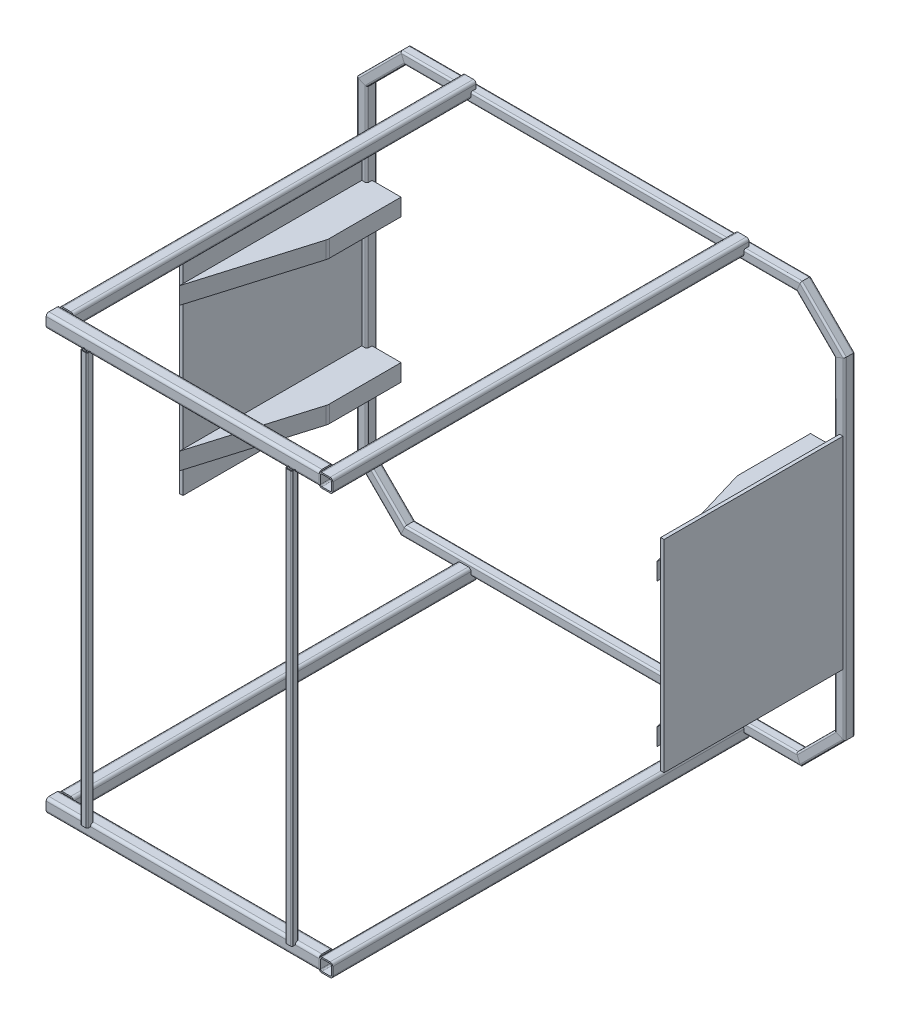
from build123d import *

# Parameters (mm, degrees)
SQUARE_TUBE_CONFIGURED_30_X_30_X_2_6_1_DEPTH      = 1169.786796564
SQUARE_TUBE_CONFIGURED_30_X_30_X_2_6_1_DEPTH_BACK = 9.786796564
SQUARE_TUBE_CONFIGURED_30_X_30_X_2_4_DEPTH        = 189.279220614
SQUARE_TUBE_CONFIGURED_30_X_30_X_2_6_DEPTH        = 979.573593129
SQUARE_TUBE_CONFIGURED_30_X_30_X_2_8_DEPTH        = 189.279220614
SQUARE_TUBE_CONFIGURED_30_X_30_X_2_10_DEPTH       = 1179.573593129
SQUARE_TUBE_CONFIGURED_30_X_30_X_2_13_DEPTH       = 189.279220614
SQUARE_TUBE_CONFIGURED_30_X_30_X_2_16_DEPTH       = 979.573593129
SQUARE_TUBE_CONFIGURED_30_X_30_X_2_19_DEPTH       = 189.279220614
SQUARE_TUBE_CONFIGURED_40_X_40_X_4_1_DEPTH        = 1220
SQUARE_TUBE_CONFIGURED_40_X_40_X_4_1_2_DEPTH      = 821
SQUARE_TUBE_CONFIGURED_40_X_40_X_4_1_3_DEPTH      = 1201
SQUARE_TUBE_CONFIGURED_40_X_40_X_4_4_DEPTH        = 1220
SQUARE_TUBE_CONFIGURED_40_X_40_X_4_4_2_DEPTH      = 821
SQUARE_TUBE_CONFIGURED_40_X_40_X_4_4_3_DEPTH      = 1201
SQUARE_TUBE_CONFIGURED_20_X_20_X_2_1_DEPTH        = 1206
SQUARE_TUBE_CONFIGURED_20_X_20_X_2_1_2_DEPTH      = 1206
DODANIE_WYCI_GNI_CIE1_DEPTH                       = 50
SZYK_LINIOWY1_COUNT                               = 2
SZYK_LINIOWY1_PITCH                               = 420
LUSTRO1_COPY_1_DEPTH                              = 50
SZKIC14_W                                         = 539.262552896
SZKIC14_H                                         = 591.984283132
DODANIE_WYCI_GNI_CIE2_DEPTH                       = 10
SZKIC15_W                                         = 539.262552896
SZKIC15_H                                         = 593.627508771
DODANIE_WYCI_GNI_CIE3_DEPTH                       = 10


with BuildPart() as part:
    # Sketch1 → Square tube - configured 30 X 30 X 2.6(1) (new, two sides)
    with BuildSketch(Plane(origin=(-580, 600, 0), x_dir=(0, 0, -1), z_dir=(1, 0, 0))) as square_tube_configured_30_x_30_x_2_6_1_sk:
        with BuildLine():
            Line((-9.8, -15), (9.8, -15))
            ThreePointArc((9.8, -15), (13.476955262, -13.476955262), (15, -9.8))
            Line((15, -9.8), (15, 9.8))
            ThreePointArc((15, 9.8), (13.476955262, 13.476955262), (9.8, 15))
            Line((9.8, 15), (-9.8, 15))
            ThreePointArc((-9.8, 15), (-13.476955262, 13.476955262), (-15, 9.8))
            Line((-15, 9.8), (-15, -9.8))
            ThreePointArc((-15, -9.8), (-13.476955262, -13.476955262), (-9.8, -15))
        make_face()
        with BuildLine():
            Line((-9.8, -12.4), (9.8, -12.4))
            ThreePointArc((9.8, -12.4), (11.638477631, -11.638477631), (12.4, -9.8))
            Line((12.4, -9.8), (12.4, 9.8))
            ThreePointArc((12.4, 9.8), (11.638477631, 11.638477631), (9.8, 12.4))
            Line((9.8, 12.4), (-9.8, 12.4))
            ThreePointArc((-9.8, 12.4), (-11.638477631, 11.638477631), (-12.4, 9.8))
            Line((-12.4, 9.8), (-12.4, -9.8))
            ThreePointArc((-12.4, -9.8), (-11.638477631, -11.638477631), (-9.8, -12.4))
        make_face(mode=Mode.SUBTRACT)
    extrude(amount=SQUARE_TUBE_CONFIGURED_30_X_30_X_2_6_1_DEPTH)
    extrude(square_tube_configured_30_x_30_x_2_6_1_sk.sketch, amount=-SQUARE_TUBE_CONFIGURED_30_X_30_X_2_6_1_DEPTH_BACK)

    # Square tube - configured 30 X 30 X 2 2
    split(bisect_by=Plane(origin=(-580, 600, 0), x_dir=(-0.382683432, 0.923879533, 0), z_dir=(0.923879533, 0.382683432, 0)), keep=Keep.TOP)

    # Square tube - configured 30 X 30 X 2 3
    split(bisect_by=Plane(origin=(580, 600, 0), x_dir=(-0.382683432, -0.923879533, 0), z_dir=(-0.923879533, 0.382683432, 0)), keep=Keep.TOP)


with BuildPart() as body_2:
    # Sketch1 on segment 2 (carried to segment 2) → Square tube - configured 30 X 30 X 2 4 (new body)
    with BuildSketch(Plane(origin=(573.079689783, 606.920310217, 0), x_dir=(0, 0, -1), z_dir=(0.707106781, -0.707106781, 0))):
        with BuildLine():
            Line((-9.8, -15), (9.8, -15))
            ThreePointArc((9.8, -15), (13.476955262, -13.476955262), (15, -9.8))
            Line((15, -9.8), (15, 9.8))
            ThreePointArc((15, 9.8), (13.476955262, 13.476955262), (9.8, 15))
            Line((9.8, 15), (-9.8, 15))
            ThreePointArc((-9.8, 15), (-13.476955262, 13.476955262), (-15, 9.8))
            Line((-15, 9.8), (-15, -9.8))
            ThreePointArc((-15, -9.8), (-13.476955262, -13.476955262), (-9.8, -15))
        make_face()
        with BuildLine():
            Line((-9.8, -12.4), (9.8, -12.4))
            ThreePointArc((9.8, -12.4), (11.638477631, -11.638477631), (12.4, -9.8))
            Line((12.4, -9.8), (12.4, 9.8))
            ThreePointArc((12.4, 9.8), (11.638477631, 11.638477631), (9.8, 12.4))
            Line((9.8, 12.4), (-9.8, 12.4))
            ThreePointArc((-9.8, 12.4), (-11.638477631, 11.638477631), (-12.4, 9.8))
            Line((-12.4, 9.8), (-12.4, -9.8))
            ThreePointArc((-12.4, -9.8), (-11.638477631, -11.638477631), (-9.8, -12.4))
        make_face(mode=Mode.SUBTRACT)
    extrude(amount=SQUARE_TUBE_CONFIGURED_30_X_30_X_2_4_DEPTH)

    # Square tube - configured 30 X 30 X 2 4 m
    split(bisect_by=Plane(origin=(580, 600, 0), x_dir=(0.382683432, 0.923879533, 0), z_dir=(0.923879533, -0.382683432, 0)), keep=Keep.TOP)

    # Square tube - configured 30 X 30 X 2 5
    split(bisect_by=Plane(origin=(700, 480, 0), x_dir=(-0.923879533, -0.382683432, 0), z_dir=(-0.382683432, 0.923879533, 0)), keep=Keep.TOP)


with BuildPart() as body_3:
    # Sketch1 on segment 3 (carried to segment 3) → Square tube - configured 30 X 30 X 2 6 (new body)
    with BuildSketch(Plane(origin=(700, 489.786796564, 0), x_dir=(0, 0, -1), z_dir=(0, -1, 0))):
        with BuildLine():
            Line((-9.8, -15), (9.8, -15))
            ThreePointArc((9.8, -15), (13.476955262, -13.476955262), (15, -9.8))
            Line((15, -9.8), (15, 9.8))
            ThreePointArc((15, 9.8), (13.476955262, 13.476955262), (9.8, 15))
            Line((9.8, 15), (-9.8, 15))
            ThreePointArc((-9.8, 15), (-13.476955262, 13.476955262), (-15, 9.8))
            Line((-15, 9.8), (-15, -9.8))
            ThreePointArc((-15, -9.8), (-13.476955262, -13.476955262), (-9.8, -15))
        make_face()
        with BuildLine():
            Line((-9.8, -12.4), (9.8, -12.4))
            ThreePointArc((9.8, -12.4), (11.638477631, -11.638477631), (12.4, -9.8))
            Line((12.4, -9.8), (12.4, 9.8))
            ThreePointArc((12.4, 9.8), (11.638477631, 11.638477631), (9.8, 12.4))
            Line((9.8, 12.4), (-9.8, 12.4))
            ThreePointArc((-9.8, 12.4), (-11.638477631, 11.638477631), (-12.4, 9.8))
            Line((-12.4, 9.8), (-12.4, -9.8))
            ThreePointArc((-12.4, -9.8), (-11.638477631, -11.638477631), (-9.8, -12.4))
        make_face(mode=Mode.SUBTRACT)
    extrude(amount=SQUARE_TUBE_CONFIGURED_30_X_30_X_2_6_DEPTH)

    # Square tube - configured 30 X 30 X 2 6 m
    split(bisect_by=Plane(origin=(700, 480, 0), x_dir=(0.923879533, 0.382683432, 0), z_dir=(0.382683432, -0.923879533, 0)), keep=Keep.TOP)

    # Square tube - configured 30 X 30 X 2 7
    split(bisect_by=Plane(origin=(700, -480, 0), x_dir=(-0.923879533, 0.382683432, 0), z_dir=(0.382683432, 0.923879533, 0)), keep=Keep.TOP)


with BuildPart() as body_4:
    # Sketch1 on segment 4 (carried to segment 4) → Square tube - configured 30 X 30 X 2 8 (new body)
    with BuildSketch(Plane(origin=(706.920310217, -473.079689783, 0), x_dir=(0, 0, -1), z_dir=(-0.707106781, -0.707106781, 0))):
        with BuildLine():
            Line((-9.8, -15), (9.8, -15))
            ThreePointArc((9.8, -15), (13.476955262, -13.476955262), (15, -9.8))
            Line((15, -9.8), (15, 9.8))
            ThreePointArc((15, 9.8), (13.476955262, 13.476955262), (9.8, 15))
            Line((9.8, 15), (-9.8, 15))
            ThreePointArc((-9.8, 15), (-13.476955262, 13.476955262), (-15, 9.8))
            Line((-15, 9.8), (-15, -9.8))
            ThreePointArc((-15, -9.8), (-13.476955262, -13.476955262), (-9.8, -15))
        make_face()
        with BuildLine():
            Line((-9.8, -12.4), (9.8, -12.4))
            ThreePointArc((9.8, -12.4), (11.638477631, -11.638477631), (12.4, -9.8))
            Line((12.4, -9.8), (12.4, 9.8))
            ThreePointArc((12.4, 9.8), (11.638477631, 11.638477631), (9.8, 12.4))
            Line((9.8, 12.4), (-9.8, 12.4))
            ThreePointArc((-9.8, 12.4), (-11.638477631, 11.638477631), (-12.4, 9.8))
            Line((-12.4, 9.8), (-12.4, -9.8))
            ThreePointArc((-12.4, -9.8), (-11.638477631, -11.638477631), (-9.8, -12.4))
        make_face(mode=Mode.SUBTRACT)
    extrude(amount=SQUARE_TUBE_CONFIGURED_30_X_30_X_2_8_DEPTH)

    # Square tube - configured 30 X 30 X 2 8 m
    split(bisect_by=Plane(origin=(700, -480, 0), x_dir=(0.923879533, -0.382683432, 0), z_dir=(-0.382683432, -0.923879533, 0)), keep=Keep.TOP)

    # Square tube - configured 30 X 30 X 2 9
    split(bisect_by=Plane(origin=(580, -600, 0), x_dir=(-0.382683432, 0.923879533, 0), z_dir=(0.923879533, 0.382683432, 0)), keep=Keep.TOP)


with BuildPart() as body_5:
    # Sketch1 on segment 5 (carried to segment 5) → Square tube - configured 30 X 30 X 2 10 (new body)
    with BuildSketch(Plane(origin=(589.786796564, -600, 0), x_dir=(0, 0, -1), z_dir=(-1, 0, 0))):
        with BuildLine():
            Line((-9.8, -15), (9.8, -15))
            ThreePointArc((9.8, -15), (13.476955262, -13.476955262), (15, -9.8))
            Line((15, -9.8), (15, 9.8))
            ThreePointArc((15, 9.8), (13.476955262, 13.476955262), (9.8, 15))
            Line((9.8, 15), (-9.8, 15))
            ThreePointArc((-9.8, 15), (-13.476955262, 13.476955262), (-15, 9.8))
            Line((-15, 9.8), (-15, -9.8))
            ThreePointArc((-15, -9.8), (-13.476955262, -13.476955262), (-9.8, -15))
        make_face()
        with BuildLine():
            Line((-9.8, -12.4), (9.8, -12.4))
            ThreePointArc((9.8, -12.4), (11.638477631, -11.638477631), (12.4, -9.8))
            Line((12.4, -9.8), (12.4, 9.8))
            ThreePointArc((12.4, 9.8), (11.638477631, 11.638477631), (9.8, 12.4))
            Line((9.8, 12.4), (-9.8, 12.4))
            ThreePointArc((-9.8, 12.4), (-11.638477631, 11.638477631), (-12.4, 9.8))
            Line((-12.4, 9.8), (-12.4, -9.8))
            ThreePointArc((-12.4, -9.8), (-11.638477631, -11.638477631), (-9.8, -12.4))
        make_face(mode=Mode.SUBTRACT)
    extrude(amount=SQUARE_TUBE_CONFIGURED_30_X_30_X_2_10_DEPTH)

    # Square tube - configured 30 X 30 X 2 11
    split(bisect_by=Plane(origin=(-580, -600, 0), x_dir=(0.382683432, 0.923879533, 0), z_dir=(0.923879533, -0.382683432, 0)), keep=Keep.TOP)

    # Square tube - configured 30 X 30 X 2 12
    split(bisect_by=Plane(origin=(580, -600, 0), x_dir=(0.382683432, -0.923879533, 0), z_dir=(-0.923879533, -0.382683432, 0)), keep=Keep.TOP)


with BuildPart() as body_6:
    # Sketch1 on segment 6 (carried to segment 6) → Square tube - configured 30 X 30 X 2 13 (new body)
    with BuildSketch(Plane(origin=(-573.079689783, -606.920310217, 0), x_dir=(0, 0, -1), z_dir=(-0.707106781, 0.707106781, 0))):
        with BuildLine():
            Line((-9.8, -15), (9.8, -15))
            ThreePointArc((9.8, -15), (13.476955262, -13.476955262), (15, -9.8))
            Line((15, -9.8), (15, 9.8))
            ThreePointArc((15, 9.8), (13.476955262, 13.476955262), (9.8, 15))
            Line((9.8, 15), (-9.8, 15))
            ThreePointArc((-9.8, 15), (-13.476955262, 13.476955262), (-15, 9.8))
            Line((-15, 9.8), (-15, -9.8))
            ThreePointArc((-15, -9.8), (-13.476955262, -13.476955262), (-9.8, -15))
        make_face()
        with BuildLine():
            Line((-9.8, -12.4), (9.8, -12.4))
            ThreePointArc((9.8, -12.4), (11.638477631, -11.638477631), (12.4, -9.8))
            Line((12.4, -9.8), (12.4, 9.8))
            ThreePointArc((12.4, 9.8), (11.638477631, 11.638477631), (9.8, 12.4))
            Line((9.8, 12.4), (-9.8, 12.4))
            ThreePointArc((-9.8, 12.4), (-11.638477631, 11.638477631), (-12.4, 9.8))
            Line((-12.4, 9.8), (-12.4, -9.8))
            ThreePointArc((-12.4, -9.8), (-11.638477631, -11.638477631), (-9.8, -12.4))
        make_face(mode=Mode.SUBTRACT)
    extrude(amount=SQUARE_TUBE_CONFIGURED_30_X_30_X_2_13_DEPTH)

    # Square tube - configured 30 X 30 X 2 14
    split(bisect_by=Plane(origin=(-700, -480, 0), x_dir=(0.923879533, 0.382683432, 0), z_dir=(0.382683432, -0.923879533, 0)), keep=Keep.TOP)

    # Square tube - configured 30 X 30 X 2 15
    split(bisect_by=Plane(origin=(-580, -600, 0), x_dir=(-0.382683432, -0.923879533, 0), z_dir=(-0.923879533, 0.382683432, 0)), keep=Keep.TOP)


with BuildPart() as body_7:
    # Sketch1 on segment 7 (carried to segment 7) → Square tube - configured 30 X 30 X 2 16 (new body)
    with BuildSketch(Plane(origin=(-700, -489.786796564, 0), x_dir=(0, 0, -1), z_dir=(0, 1, 0))):
        with BuildLine():
            Line((-9.8, -15), (9.8, -15))
            ThreePointArc((9.8, -15), (13.476955262, -13.476955262), (15, -9.8))
            Line((15, -9.8), (15, 9.8))
            ThreePointArc((15, 9.8), (13.476955262, 13.476955262), (9.8, 15))
            Line((9.8, 15), (-9.8, 15))
            ThreePointArc((-9.8, 15), (-13.476955262, 13.476955262), (-15, 9.8))
            Line((-15, 9.8), (-15, -9.8))
            ThreePointArc((-15, -9.8), (-13.476955262, -13.476955262), (-9.8, -15))
        make_face()
        with BuildLine():
            Line((-9.8, -12.4), (9.8, -12.4))
            ThreePointArc((9.8, -12.4), (11.638477631, -11.638477631), (12.4, -9.8))
            Line((12.4, -9.8), (12.4, 9.8))
            ThreePointArc((12.4, 9.8), (11.638477631, 11.638477631), (9.8, 12.4))
            Line((9.8, 12.4), (-9.8, 12.4))
            ThreePointArc((-9.8, 12.4), (-11.638477631, 11.638477631), (-12.4, 9.8))
            Line((-12.4, 9.8), (-12.4, -9.8))
            ThreePointArc((-12.4, -9.8), (-11.638477631, -11.638477631), (-9.8, -12.4))
        make_face(mode=Mode.SUBTRACT)
    extrude(amount=SQUARE_TUBE_CONFIGURED_30_X_30_X_2_16_DEPTH)

    # Square tube - configured 30 X 30 X 2 17
    split(bisect_by=Plane(origin=(-700, 480, 0), x_dir=(0.923879533, -0.382683432, 0), z_dir=(-0.382683432, -0.923879533, 0)), keep=Keep.TOP)

    # Square tube - configured 30 X 30 X 2 18
    split(bisect_by=Plane(origin=(-700, -480, 0), x_dir=(-0.923879533, -0.382683432, 0), z_dir=(-0.382683432, 0.923879533, 0)), keep=Keep.TOP)


with BuildPart() as body_8:
    # Sketch1 on segment 8 (carried to segment 8) → Square tube - configured 30 X 30 X 2 19 (new body)
    with BuildSketch(Plane(origin=(-706.920310217, 473.079689783, 0), x_dir=(0, 0, -1), z_dir=(0.707106781, 0.707106781, 0))):
        with BuildLine():
            Line((-9.8, -15), (9.8, -15))
            ThreePointArc((9.8, -15), (13.476955262, -13.476955262), (15, -9.8))
            Line((15, -9.8), (15, 9.8))
            ThreePointArc((15, 9.8), (13.476955262, 13.476955262), (9.8, 15))
            Line((9.8, 15), (-9.8, 15))
            ThreePointArc((-9.8, 15), (-13.476955262, 13.476955262), (-15, 9.8))
            Line((-15, 9.8), (-15, -9.8))
            ThreePointArc((-15, -9.8), (-13.476955262, -13.476955262), (-9.8, -15))
        make_face()
        with BuildLine():
            Line((-9.8, -12.4), (9.8, -12.4))
            ThreePointArc((9.8, -12.4), (11.638477631, -11.638477631), (12.4, -9.8))
            Line((12.4, -9.8), (12.4, 9.8))
            ThreePointArc((12.4, 9.8), (11.638477631, 11.638477631), (9.8, 12.4))
            Line((9.8, 12.4), (-9.8, 12.4))
            ThreePointArc((-9.8, 12.4), (-11.638477631, 11.638477631), (-12.4, 9.8))
            Line((-12.4, 9.8), (-12.4, -9.8))
            ThreePointArc((-12.4, -9.8), (-11.638477631, -11.638477631), (-9.8, -12.4))
        make_face(mode=Mode.SUBTRACT)
    extrude(amount=SQUARE_TUBE_CONFIGURED_30_X_30_X_2_19_DEPTH)

    # Square tube - configured 30 X 30 X 2 20
    split(bisect_by=Plane(origin=(-580, 600, 0), x_dir=(0.382683432, -0.923879533, 0), z_dir=(-0.923879533, -0.382683432, 0)), keep=Keep.TOP)

    # Square tube - configured 30 X 30 X 2 21
    split(bisect_by=Plane(origin=(-700, 480, 0), x_dir=(-0.923879533, 0.382683432, 0), z_dir=(0.382683432, 0.923879533, 0)), keep=Keep.TOP)


with BuildPart() as body_9:
    # Sketch13 → Square tube - configured 40 X 40 X 4(1) (new body)
    with BuildSketch(Plane(origin=(400, 615, 0), x_dir=(1, 0, 0), z_dir=(0, 0, 1))):
        with BuildLine():
            Line((-12, -20), (12, -20))
            ThreePointArc((12, -20), (17.656854249, -17.656854249), (20, -12))
            Line((20, -12), (20, 12))
            ThreePointArc((20, 12), (17.656854249, 17.656854249), (12, 20))
            Line((12, 20), (-12, 20))
            ThreePointArc((-12, 20), (-17.656854249, 17.656854249), (-20, 12))
            Line((-20, 12), (-20, -12))
            ThreePointArc((-20, -12), (-17.656854249, -17.656854249), (-12, -20))
        make_face()
        with BuildLine():
            Line((-12, -16), (12, -16))
            ThreePointArc((12, -16), (14.828427125, -14.828427125), (16, -12))
            Line((16, -12), (16, 12))
            ThreePointArc((16, 12), (14.828427125, 14.828427125), (12, 16))
            Line((12, 16), (-12, 16))
            ThreePointArc((-12, 16), (-14.828427125, 14.828427125), (-16, 12))
            Line((-16, 12), (-16, -12))
            ThreePointArc((-16, -12), (-14.828427125, -14.828427125), (-12, -16))
        make_face(mode=Mode.SUBTRACT)
    extrude(amount=SQUARE_TUBE_CONFIGURED_40_X_40_X_4_1_DEPTH)


with BuildPart() as body_10:
    # Sketch13 on segment 2 (carried to segment 2) → Square tube - configured 40 X 40 X 4_1 2 (new body)
    with BuildSketch(Plane(origin=(401, 615, 1200), x_dir=(0, 0, 1), z_dir=(-1, 0, 0))):
        with BuildLine():
            Line((-12, -20), (12, -20))
            ThreePointArc((12, -20), (17.656854249, -17.656854249), (20, -12))
            Line((20, -12), (20, 12))
            ThreePointArc((20, 12), (17.656854249, 17.656854249), (12, 20))
            Line((12, 20), (-12, 20))
            ThreePointArc((-12, 20), (-17.656854249, 17.656854249), (-20, 12))
            Line((-20, 12), (-20, -12))
            ThreePointArc((-20, -12), (-17.656854249, -17.656854249), (-12, -20))
        make_face()
        with BuildLine():
            Line((-12, -16), (12, -16))
            ThreePointArc((12, -16), (14.828427125, -14.828427125), (16, -12))
            Line((16, -12), (16, 12))
            ThreePointArc((16, 12), (14.828427125, 14.828427125), (12, 16))
            Line((12, 16), (-12, 16))
            ThreePointArc((-12, 16), (-14.828427125, 14.828427125), (-16, 12))
            Line((-16, 12), (-16, -12))
            ThreePointArc((-16, -12), (-14.828427125, -14.828427125), (-12, -16))
        make_face(mode=Mode.SUBTRACT)
    extrude(amount=SQUARE_TUBE_CONFIGURED_40_X_40_X_4_1_2_DEPTH)

    # Square tube - configured 40 X 40 X 4 2
    split(bisect_by=Plane(origin=(380, 615, 1200), x_dir=(0, -1, 0), z_dir=(-1, 0, 0)), keep=Keep.TOP)


with BuildPart() as body_11:
    # Sketch13 on segment 3 (carried to segment 3) → Square tube - configured 40 X 40 X 4_1 3 (new body)
    with BuildSketch(Plane(origin=(-400, 615, 1201), x_dir=(-1, 0, 0), z_dir=(0, 0, -1))):
        with BuildLine():
            Line((-12, -20), (12, -20))
            ThreePointArc((12, -20), (17.656854249, -17.656854249), (20, -12))
            Line((20, -12), (20, 12))
            ThreePointArc((20, 12), (17.656854249, 17.656854249), (12, 20))
            Line((12, 20), (-12, 20))
            ThreePointArc((-12, 20), (-17.656854249, 17.656854249), (-20, 12))
            Line((-20, 12), (-20, -12))
            ThreePointArc((-20, -12), (-17.656854249, -17.656854249), (-12, -20))
        make_face()
        with BuildLine():
            Line((-12, -16), (12, -16))
            ThreePointArc((12, -16), (14.828427125, -14.828427125), (16, -12))
            Line((16, -12), (16, 12))
            ThreePointArc((16, 12), (14.828427125, 14.828427125), (12, 16))
            Line((12, 16), (-12, 16))
            ThreePointArc((-12, 16), (-14.828427125, 14.828427125), (-16, 12))
            Line((-16, 12), (-16, -12))
            ThreePointArc((-16, -12), (-14.828427125, -14.828427125), (-12, -16))
        make_face(mode=Mode.SUBTRACT)
    extrude(amount=SQUARE_TUBE_CONFIGURED_40_X_40_X_4_1_3_DEPTH)

    # Square tube - configured 40 X 40 X 4 3
    split(bisect_by=Plane(origin=(-400, 615, 1180), x_dir=(0, 1, 0), z_dir=(0, 0, -1)), keep=Keep.TOP)


with BuildPart() as body_12:
    # Sketch14 → Square tube - configured 40 X 40 X 4 4 (new body)
    with BuildSketch(Plane(origin=(400, -615, 0), x_dir=(-1, 0, 0), z_dir=(0, 0, 1))):
        with BuildLine():
            Line((-12, -20), (12, -20))
            ThreePointArc((12, -20), (17.656854249, -17.656854249), (20, -12))
            Line((20, -12), (20, 12))
            ThreePointArc((20, 12), (17.656854249, 17.656854249), (12, 20))
            Line((12, 20), (-12, 20))
            ThreePointArc((-12, 20), (-17.656854249, 17.656854249), (-20, 12))
            Line((-20, 12), (-20, -12))
            ThreePointArc((-20, -12), (-17.656854249, -17.656854249), (-12, -20))
        make_face()
        with BuildLine():
            Line((-12, -16), (12, -16))
            ThreePointArc((12, -16), (14.828427125, -14.828427125), (16, -12))
            Line((16, -12), (16, 12))
            ThreePointArc((16, 12), (14.828427125, 14.828427125), (12, 16))
            Line((12, 16), (-12, 16))
            ThreePointArc((-12, 16), (-14.828427125, 14.828427125), (-16, 12))
            Line((-16, 12), (-16, -12))
            ThreePointArc((-16, -12), (-14.828427125, -14.828427125), (-12, -16))
        make_face(mode=Mode.SUBTRACT)
    extrude(amount=SQUARE_TUBE_CONFIGURED_40_X_40_X_4_4_DEPTH)


with BuildPart() as body_13:
    # Sketch14 on segment 2 (carried to segment 2) → Square tube - configured 40 X 40 X 4 4 2 (new body)
    with BuildSketch(Plane(origin=(401, -615, 1200), x_dir=(0, 0, -1), z_dir=(-1, 0, 0))):
        with BuildLine():
            Line((-12, -20), (12, -20))
            ThreePointArc((12, -20), (17.656854249, -17.656854249), (20, -12))
            Line((20, -12), (20, 12))
            ThreePointArc((20, 12), (17.656854249, 17.656854249), (12, 20))
            Line((12, 20), (-12, 20))
            ThreePointArc((-12, 20), (-17.656854249, 17.656854249), (-20, 12))
            Line((-20, 12), (-20, -12))
            ThreePointArc((-20, -12), (-17.656854249, -17.656854249), (-12, -20))
        make_face()
        with BuildLine():
            Line((-12, -16), (12, -16))
            ThreePointArc((12, -16), (14.828427125, -14.828427125), (16, -12))
            Line((16, -12), (16, 12))
            ThreePointArc((16, 12), (14.828427125, 14.828427125), (12, 16))
            Line((12, 16), (-12, 16))
            ThreePointArc((-12, 16), (-14.828427125, 14.828427125), (-16, 12))
            Line((-16, 12), (-16, -12))
            ThreePointArc((-16, -12), (-14.828427125, -14.828427125), (-12, -16))
        make_face(mode=Mode.SUBTRACT)
    extrude(amount=SQUARE_TUBE_CONFIGURED_40_X_40_X_4_4_2_DEPTH)

    # Square tube - configured 40 X 40 X 4 5
    split(bisect_by=Plane(origin=(380, -615, 1200), x_dir=(0, -1, 0), z_dir=(-1, 0, 0)), keep=Keep.TOP)


with BuildPart() as body_14:
    # Sketch14 on segment 3 (carried to segment 3) → Square tube - configured 40 X 40 X 4 4 3 (new body)
    with BuildSketch(Plane(origin=(-400, -615, 1201), x_dir=(1, 0, 0), z_dir=(0, 0, -1))):
        with BuildLine():
            Line((-12, -20), (12, -20))
            ThreePointArc((12, -20), (17.656854249, -17.656854249), (20, -12))
            Line((20, -12), (20, 12))
            ThreePointArc((20, 12), (17.656854249, 17.656854249), (12, 20))
            Line((12, 20), (-12, 20))
            ThreePointArc((-12, 20), (-17.656854249, 17.656854249), (-20, 12))
            Line((-20, 12), (-20, -12))
            ThreePointArc((-20, -12), (-17.656854249, -17.656854249), (-12, -20))
        make_face()
        with BuildLine():
            Line((-12, -16), (12, -16))
            ThreePointArc((12, -16), (14.828427125, -14.828427125), (16, -12))
            Line((16, -12), (16, 12))
            ThreePointArc((16, 12), (14.828427125, 14.828427125), (12, 16))
            Line((12, 16), (-12, 16))
            ThreePointArc((-12, 16), (-14.828427125, 14.828427125), (-16, 12))
            Line((-16, 12), (-16, -12))
            ThreePointArc((-16, -12), (-14.828427125, -14.828427125), (-12, -16))
        make_face(mode=Mode.SUBTRACT)
    extrude(amount=SQUARE_TUBE_CONFIGURED_40_X_40_X_4_4_3_DEPTH)

    # Square tube - configured 40 X 40 X 4 6
    split(bisect_by=Plane(origin=(-400, -615, 1180), x_dir=(0, 1, 0), z_dir=(0, 0, -1)), keep=Keep.TOP)


with BuildPart() as body_15:
    # Sketch16 → Square tube - configured 20 X 20 X 2(1) (new body)
    with BuildSketch(Plane(origin=(300, -603, 1220), x_dir=(-1, 0, 0), z_dir=(0, 1, 0))):
        with BuildLine():
            Line((-6, -10), (6, -10))
            ThreePointArc((6, -10), (8.828427125, -8.828427125), (10, -6))
            Line((10, -6), (10, 6))
            ThreePointArc((10, 6), (8.828427125, 8.828427125), (6, 10))
            Line((6, 10), (-6, 10))
            ThreePointArc((-6, 10), (-8.828427125, 8.828427125), (-10, 6))
            Line((-10, 6), (-10, -6))
            ThreePointArc((-10, -6), (-8.828427125, -8.828427125), (-6, -10))
        make_face()
        with BuildLine():
            Line((-6, -8), (6, -8))
            ThreePointArc((6, -8), (7.414213562, -7.414213562), (8, -6))
            Line((8, -6), (8, 6))
            ThreePointArc((8, 6), (7.414213562, 7.414213562), (6, 8))
            Line((6, 8), (-6, 8))
            ThreePointArc((-6, 8), (-7.414213562, 7.414213562), (-8, 6))
            Line((-8, 6), (-8, -6))
            ThreePointArc((-8, -6), (-7.414213562, -7.414213562), (-6, -8))
        make_face(mode=Mode.SUBTRACT)
    extrude(amount=SQUARE_TUBE_CONFIGURED_20_X_20_X_2_1_DEPTH)


with BuildPart() as body_16:
    # Sketch16 on segment 2 (carried to segment 2) → Square tube - configured 20 X 20 X 2_1 2 (new body)
    with BuildSketch(Plane(origin=(-300, -603, 1220), x_dir=(-1, 0, 0), z_dir=(0, 1, 0))):
        with BuildLine():
            Line((-6, -10), (6, -10))
            ThreePointArc((6, -10), (8.828427125, -8.828427125), (10, -6))
            Line((10, -6), (10, 6))
            ThreePointArc((10, 6), (8.828427125, 8.828427125), (6, 10))
            Line((6, 10), (-6, 10))
            ThreePointArc((-6, 10), (-8.828427125, 8.828427125), (-10, 6))
            Line((-10, 6), (-10, -6))
            ThreePointArc((-10, -6), (-8.828427125, -8.828427125), (-6, -10))
        make_face()
        with BuildLine():
            Line((-6, -8), (6, -8))
            ThreePointArc((6, -8), (7.414213562, -7.414213562), (8, -6))
            Line((8, -6), (8, 6))
            ThreePointArc((8, 6), (7.414213562, 7.414213562), (6, 8))
            Line((6, 8), (-6, 8))
            ThreePointArc((-6, 8), (-7.414213562, 7.414213562), (-8, 6))
            Line((-8, 6), (-8, -6))
            ThreePointArc((-8, -6), (-7.414213562, -7.414213562), (-6, -8))
        make_face(mode=Mode.SUBTRACT)
    extrude(amount=SQUARE_TUBE_CONFIGURED_20_X_20_X_2_1_2_DEPTH)


with BuildPart() as body_17:
    # Szkic13 → Dodanie-wyciągnięcie1 (new body)
    with BuildSketch(Plane(origin=(0, 230, 0), x_dir=(1, 0, 0), z_dir=(0, 1, 0))):
        with BuildLine():
            Line((-600, 0), (-600, -210.212862363))
            ThreePointArc((-600, -210.212862363), (-600.314284894, -214.543949827), (-601.250554575, -218.784290934))
            Line((-601.250554575, -218.784290934), (-700, -550))
            Line((-700, -550), (-700, 0))
            Line((-700, 0), (-600, 0))
        make_face()
    dodanie_wyci_gni_cie1 = extrude(amount=-DODANIE_WYCI_GNI_CIE1_DEPTH)


with BuildPart() as szyk_liniowy1_1:
    # Szyk liniowy1: Dodanie-wyciągnięcie1 ×2
    with Locations(*[(0, -i * SZYK_LINIOWY1_PITCH, 0) for i in range(1, SZYK_LINIOWY1_COUNT)]):
        add(dodanie_wyci_gni_cie1)


with BuildPart() as body_3_1:
    add(body_3.part)

    # Lustro1: Dodanie-wyciągnięcie1 across plane
    add(dodanie_wyci_gni_cie1.mirror(Plane(origin=(0, 0, 0), x_dir=(0, 0, 1), z_dir=(1, 0, 0))))

    # Lustro1 copy 1 sketch → Lustro1 copy 1 (add)
    with BuildSketch(Plane(origin=(0, -190, 0), x_dir=(-1, 0, 0), z_dir=(0, 1, 0))):
        with BuildLine():
            Line((-600, 0), (-600, 210.212862363))
            ThreePointArc((-600, 210.212862363), (-600.314284894, 214.543949827), (-601.250554575, 218.784290934))
            Line((-601.250554575, 218.784290934), (-700, 550))
            Line((-700, 550), (-700, 0))
            Line((-700, 0), (-600, 0))
        make_face()
    extrude(amount=-LUSTRO1_COPY_1_DEPTH)


with BuildPart() as body_19:
    # Szkic14 → Dodanie-wyciągnięcie2 (new body)
    with BuildSketch(Plane(origin=(700, 0, 0), x_dir=(0, 0, -1), z_dir=(1, 0, 0))):
        with Locations((-269.631276448, -10.339668785)):
            Rectangle(SZKIC14_W, SZKIC14_H)
    extrude(amount=DODANIE_WYCI_GNI_CIE2_DEPTH)


with BuildPart() as body_20:
    # Szkic15 → Dodanie-wyciągnięcie3 (new body)
    with BuildSketch(Plane.ZY.offset(700)):
        with Locations((269.631276448, -11.161281605)):
            Rectangle(SZKIC15_W, SZKIC15_H)
    extrude(amount=DODANIE_WYCI_GNI_CIE3_DEPTH)


solid = Compound([part.part, body_2.part, body_4.part, body_5.part, body_6.part, body_7.part, body_8.part, body_9.part, body_10.part, body_11.part, body_12.part, body_13.part, body_14.part, body_15.part, body_16.part, body_17.part, szyk_liniowy1_1.part, body_3_1.part, body_19.part, body_20.part])
